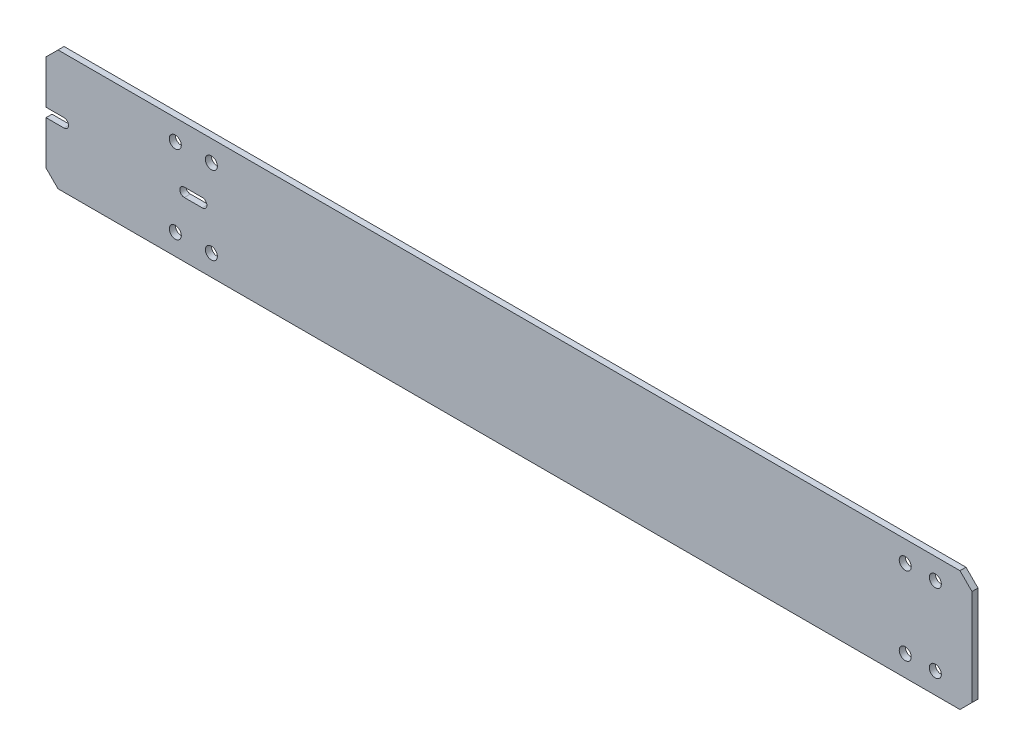
from build123d import *

# Parameters (mm, degrees)
SKETCH_1_W          = 154
SKETCH_1_H          = 20
EXTRUDE_1_DEPTH     = 0.5
CHAMFER_1_SIZE      = 2
SKETCH_2_R          = 1
CUT_EXTRUDE_1_DEPTH = 2
SKETCH_3_R          = 1
CUT_EXTRUDE_2_DEPTH = 2
SKETCH_4_W          = 3
SKETCH_4_H          = 1.5
CUT_EXTRUDE_3_DEPTH = 2
SKETCH_5_R          = 0.75
CUT_EXTRUDE_4_DEPTH = 2


with BuildPart() as part:
    # 草图1 → 凸台-拉伸1 (new body, symmetric)
    with BuildSketch(Plane.XY):
        Rectangle(SKETCH_1_W, SKETCH_1_H)
    extrude(amount=EXTRUDE_1_DEPTH, both=True)

    # 倒角1
    chamfer_1_edges = [part.edges().sort_by_distance(p)[0] for p in [
        (-77, 10, 0),
        (77, 10, 0),
        (77, -10, 0),
        (-77, -10, 0),
    ]]
    chamfer(chamfer_1_edges, length=CHAMFER_1_SIZE)

    # 草图2 → 切除-拉伸1 (cut, through all)
    with BuildSketch(Plane(origin=(0, 0, -0.5), x_dir=(-1, 0, 0), z_dir=(0, 0, -1))):
        with Locations((-70.9, -6.5)):
            Circle(SKETCH_2_R)
        with Locations((-65.9, -6.5)):
            Circle(SKETCH_2_R)
        with Locations((-65.9, 6.5)):
            Circle(SKETCH_2_R)
        with Locations((-70.9, 6.5)):
            Circle(SKETCH_2_R)
    extrude(amount=-CUT_EXTRUDE_1_DEPTH, mode=Mode.SUBTRACT)

    # 草图3 → 切除-拉伸2 (cut, through all)
    with BuildSketch(Plane(origin=(0, 0, -0.5), x_dir=(-1, 0, 0), z_dir=(0, 0, -1))):
        with Locations((55.5, 6.5)):
            Circle(SKETCH_3_R)
        with Locations((49.5, 6.5)):
            Circle(SKETCH_3_R)
        with Locations((55.5, -6.5)):
            Circle(SKETCH_3_R)
        with Locations((49.5, -6.5)):
            Circle(SKETCH_3_R)
    extrude(amount=-CUT_EXTRUDE_2_DEPTH, mode=Mode.SUBTRACT)

    # 草图4 → 切除-拉伸3 (cut, through all)
    with BuildSketch(Plane(origin=(0, 0, -0.5), x_dir=(-1, 0, 0), z_dir=(0, 0, -1))):
        with Locations((52.5, 0)):
            Rectangle(SKETCH_4_W, SKETCH_4_H)
        with Locations((75.5, 0)):
            Rectangle(SKETCH_4_W, SKETCH_4_H)
    extrude(amount=-CUT_EXTRUDE_3_DEPTH, mode=Mode.SUBTRACT)

    # 草图5 → 切除-拉伸4 (cut, through all)
    with BuildSketch(Plane(origin=(0, 0, -0.5), x_dir=(-1, 0, 0), z_dir=(0, 0, -1))):
        with Locations((51, 0)):
            Circle(SKETCH_5_R)
        with Locations((54, 0)):
            Circle(SKETCH_5_R)
        with Locations((74, 0)):
            Circle(SKETCH_5_R)
    extrude(amount=-CUT_EXTRUDE_4_DEPTH, mode=Mode.SUBTRACT)


solid = part.part
